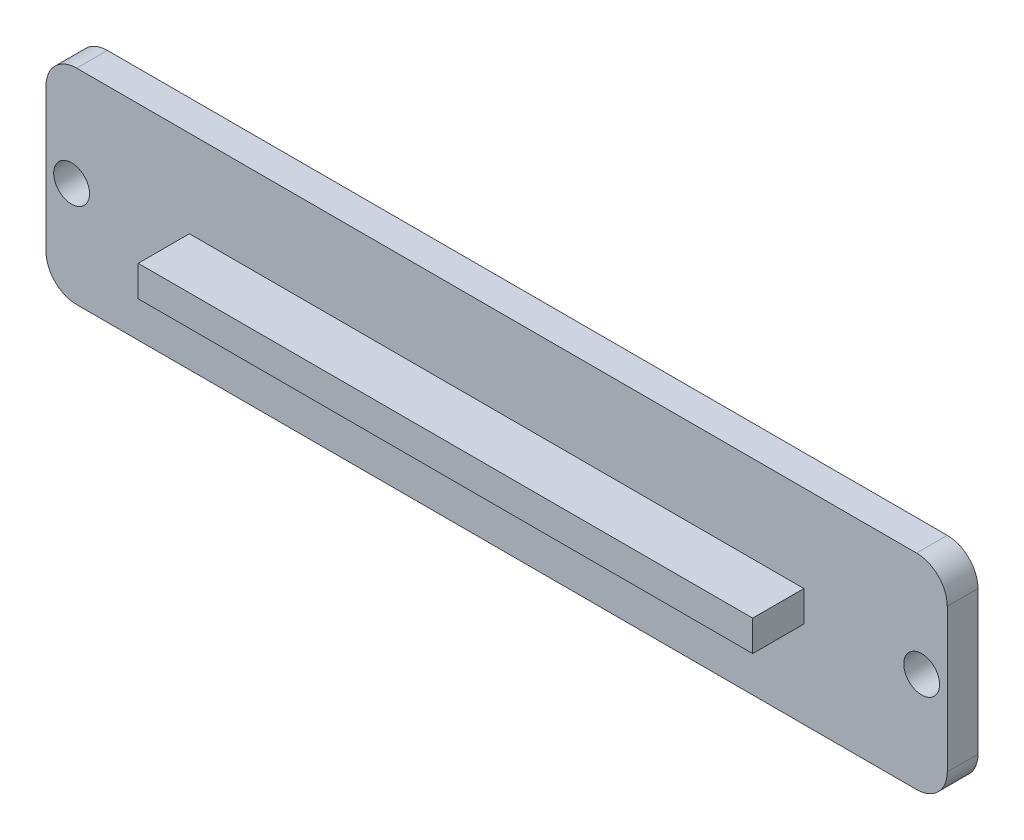
from build123d import *

# Parameters (mm, degrees)
ESQUISSE1_W        = 88
ESQUISSE1_H        = 20
ESQUISSE1_R        = 1.75
BOSS_EXTRU_1_DEPTH = 3
ESQUISSE2_W        = 60
ESQUISSE2_H        = 3
BOSS_EXTRU_2_DEPTH = 5
CONG_1_R           = 3


with BuildPart() as part:
    # Esquisse1 → Boss.-Extru.1 (new body)
    with BuildSketch(Plane.XY):
        with Locations((44, 10)):
            Rectangle(ESQUISSE1_W, ESQUISSE1_H)
        with Locations((2.5, 10)):
            Circle(ESQUISSE1_R, mode=Mode.SUBTRACT)
        with Locations((85.5, 10)):
            Circle(ESQUISSE1_R, mode=Mode.SUBTRACT)
    extrude(amount=BOSS_EXTRU_1_DEPTH)

    # Esquisse2 → Boss.-Extru.2 (add)
    with BuildSketch(Plane.XY.offset(3)):
        with Locations((44, 10)):
            Rectangle(ESQUISSE2_W, ESQUISSE2_H)
    extrude(amount=BOSS_EXTRU_2_DEPTH)

    # Congé1
    cong_1_edges = [part.edges().sort_by_distance(p)[0] for p in [
        (0, 20, 1.5),
        (88, 20, 1.5),
        (88, 0, 1.5),
        (0, 0, 1.5),
    ]]
    fillet(cong_1_edges, radius=CONG_1_R)


solid = part.part
